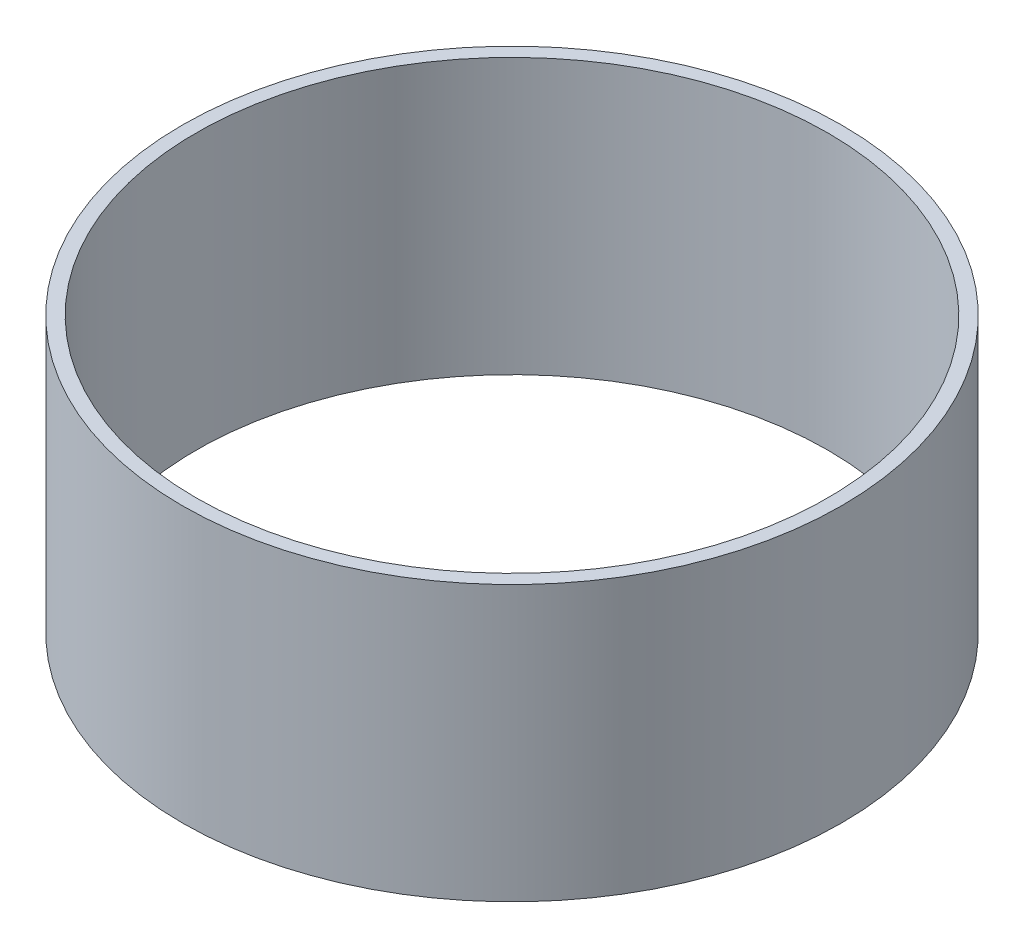
from build123d import *

# Parameters (mm, degrees)
SKETCH1_R           = 152.4
SKETCH1_R_2         = 146.05
BOSS_EXTRUDE1_DEPTH = 127


with BuildPart() as part:
    # Sketch1 → Boss-Extrude1 (new body)
    with BuildSketch(Plane(origin=(0, 0, 0), x_dir=(1, 0, 0), z_dir=(0, 1, 0))):
        Circle(SKETCH1_R)
        Circle(SKETCH1_R_2, mode=Mode.SUBTRACT)
    extrude(amount=BOSS_EXTRUDE1_DEPTH)


solid = part.part
